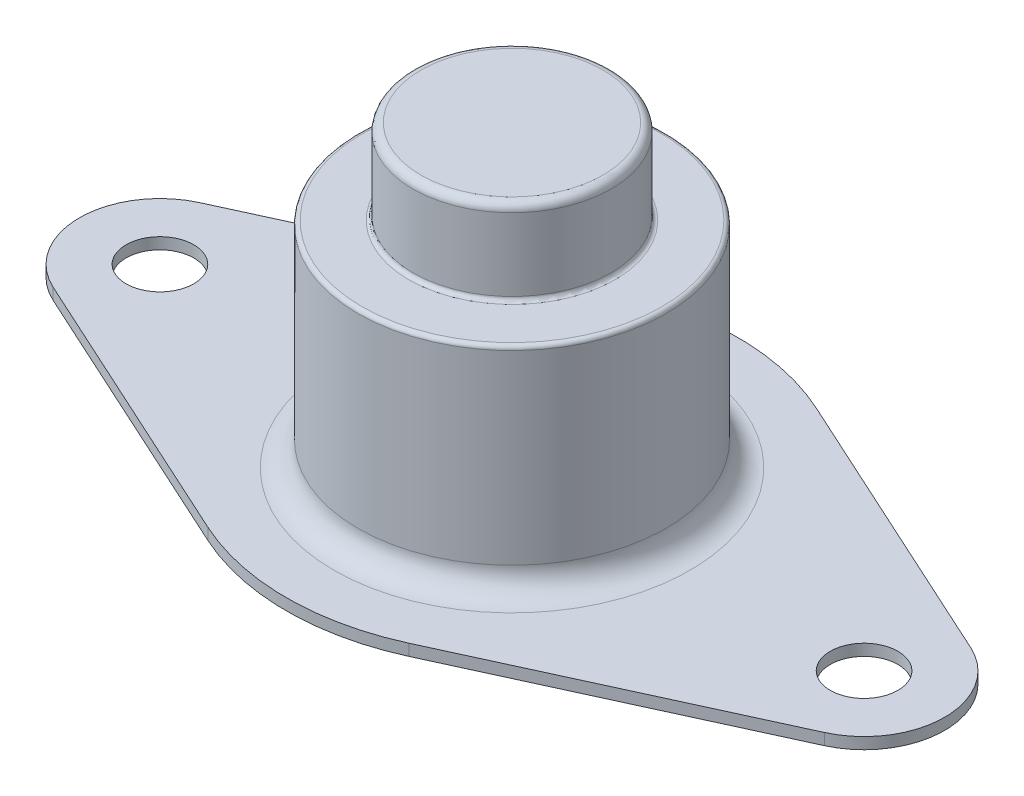
from build123d import *

# Parameters (mm, degrees)
BOSS_EXTRUDE1_DEPTH = 0.71
SKETCH4_R           = 2.1
CUT_EXTRUDE1_DEPTH  = 31.289050827
SKETCH2_R           = 9.55
BOSS_EXTRUDE2_DEPTH = 14
FILLET1_R           = 1.5
SKETCH3_R           = 6.15
BOSS_EXTRUDE3_DEPTH = 5.25
FILLET2_R           = 0.25
FILLET3_R           = 0.5
SHELL1_T            = -0.66


with BuildPart() as part:
    # Sketch1 → Boss-Extrude1 (new body)
    with BuildSketch(Plane(origin=(0, 0, 0), x_dir=(1, 0, 0), z_dir=(0, 1, 0))):
        with BuildLine():
            Line((-23.930241998, 4.546712354), (-6.240725993, 12.640137063))
            ThreePointArc((-6.240725993, 12.640137063), (0, 14), (6.240725993, 12.640137063))
            Line((6.240725993, 12.640137063), (23.930241998, 4.546712354))
            ThreePointArc((23.930241998, 4.546712354), (26.85, 0), (23.930241998, -4.546712354))
            Line((23.930241998, -4.546712354), (6.240725993, -12.640137063))
            ThreePointArc((6.240725993, -12.640137063), (0, -14), (-6.240725993, -12.640137063))
            Line((-6.240725993, -12.640137063), (-23.930241998, -4.546712354))
            ThreePointArc((-23.930241998, -4.546712354), (-26.85, 0), (-23.930241998, 4.546712354))
        make_face()
    extrude(amount=BOSS_EXTRUDE1_DEPTH)

    # Sketch4 → Cut-Extrude1 (cut, through all)
    with BuildSketch(Plane(origin=(0, 0, 0), x_dir=(1, 0, 0), z_dir=(0, 1, 0))):
        with Locations(Location((21.85, 0, 0), (0, 0, 90))):
            Circle(SKETCH4_R)
    cut_extrude1 = extrude(amount=CUT_EXTRUDE1_DEPTH, mode=Mode.SUBTRACT)

    # Sketch2 → Boss-Extrude2 (add)
    with BuildSketch(Plane(origin=(0, 0, 0), x_dir=(1, 0, 0), z_dir=(0, 1, 0))):
        with Locations(Location((0, 0, 0), (0, 0, 270))):
            Circle(SKETCH2_R)
    extrude(amount=BOSS_EXTRUDE2_DEPTH)

    # Fillet1
    fillet1_edges = [part.edges().sort_by_distance(p)[0] for p in [
        (0, 0.71, -9.55),
    ]]
    fillet(fillet1_edges, radius=FILLET1_R)

    # Sketch3 → Boss-Extrude3 (add)
    with BuildSketch(Plane(origin=(0, 14, 0), x_dir=(1, 0, 0), z_dir=(0, 1, 0))):
        with Locations(Location((0, 0, 0), (0, 0, 90))):
            Circle(SKETCH3_R)
    extrude(amount=BOSS_EXTRUDE3_DEPTH)

    # Fillet2
    fillet2_edges = [part.edges().sort_by_distance(p)[0] for p in [
        (0, 14, -9.55),
        (0, 14, 6.15),
    ]]
    fillet(fillet2_edges, radius=FILLET2_R)

    # Fillet3
    fillet3_edges = [part.edges().sort_by_distance(p)[0] for p in [
        (0, 19.25, 6.15),
    ]]
    fillet(fillet3_edges, radius=FILLET3_R)

    # Mirror1: Cut-Extrude1 across plane
    add(cut_extrude1.mirror(Plane(origin=(0, 0, 0), x_dir=(0, 0, 1), z_dir=(1, 0, 0))), mode=Mode.SUBTRACT)

    # Shell1
    shell1_openings = [part.faces().sort_by_distance(p)[0] for p in [
        (0, 0, 0),
    ]]
    offset(amount=SHELL1_T, openings=shell1_openings, kind=Kind.INTERSECTION)


solid = part.part
